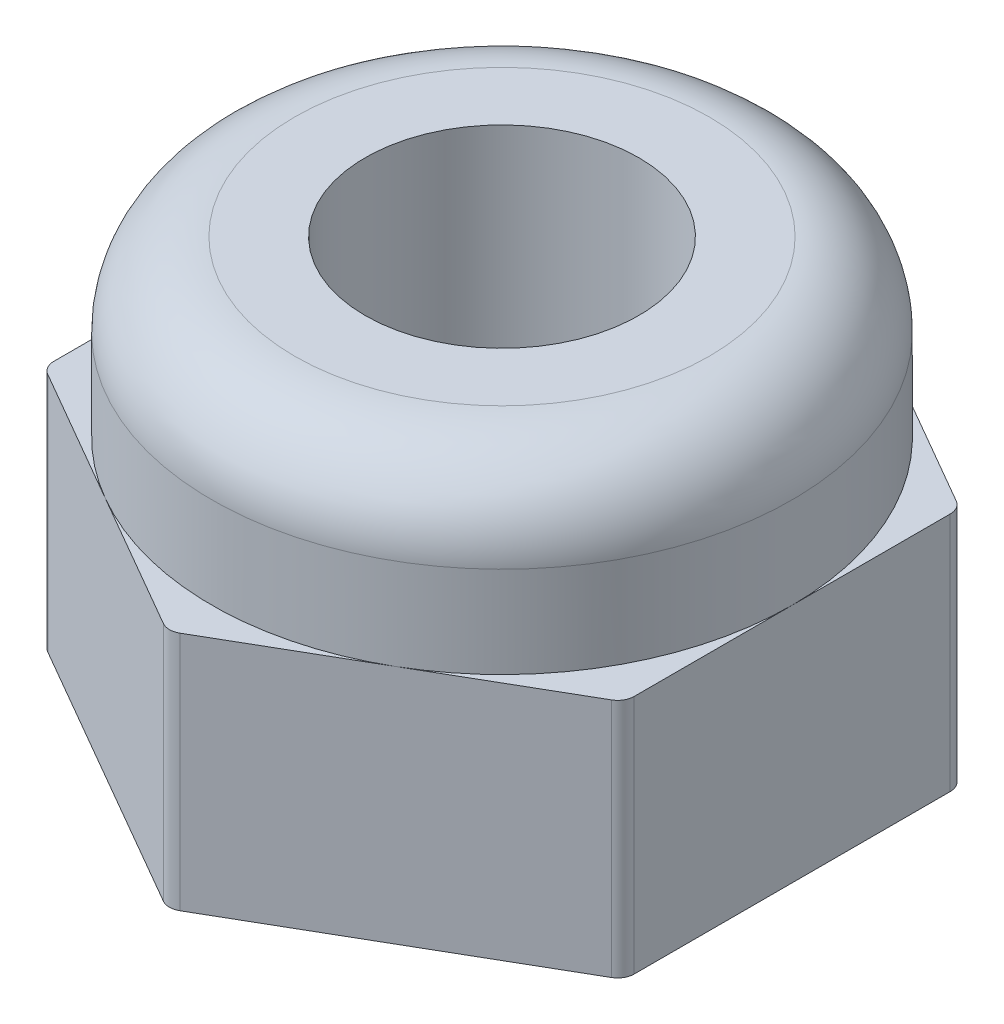
from build123d import *

# Parameters (mm, degrees)
EXTRUDE_1_DEPTH              = 2.9
SKETCH_2_R                   = 3.5
EXTRUDE_2_DEPTH              = 5
FILLET_1_R                   = 1
FILLET_2_R                   = 0.2
HOLE_WIZARD_M4_1_D           = 3.3
HOLE_WIZARD_M4_1_DEPTH       = 10.1
HOLE_WIZARD_M4_1_CSINK_D     = 4.05
HOLE_WIZARD_M4_1_CSINK_ANGLE = 90
HOLE_WIZARD_M4_1_TIP         = 0.991420021


with BuildPart() as part:
    # 草图1 → 凸台-拉伸1 (new body)
    with BuildSketch(Plane(origin=(0, 0, 0), x_dir=(1, 0, 0), z_dir=(0, 1, 0))):
        Polygon((3.5, -2.020725942), (3.5, 2.020725942), (0, 4.041451884), (-3.5, 2.020725942), (-3.5, -2.020725942), (0, -4.041451884), align=None)
    extrude(amount=EXTRUDE_1_DEPTH)

    # 草图2 → 凸台-拉伸2 (add)
    with BuildSketch(Plane.XZ):
        Circle(SKETCH_2_R)
    extrude(amount=-EXTRUDE_2_DEPTH)

    # 圆角1
    fillet_1_edges = [part.edges().sort_by_distance(p)[0] for p in [
        (-3.5, 5, 0),
    ]]
    fillet(fillet_1_edges, radius=FILLET_1_R)

    # 圆角2
    fillet_2_edges = [part.edges().sort_by_distance(p)[0] for p in [
        (0, 1.45, 4.041451884),
        (-3.5, 1.45, 2.020725942),
        (-3.5, 1.45, -2.020725942),
        (0, 1.45, -4.041451884),
        (3.5, 1.45, -2.020725942),
        (3.5, 1.45, 2.020725942),
    ]]
    fillet(fillet_2_edges, radius=FILLET_2_R)

    # M4 螺纹孔1
    with Locations(Plane(origin=(0, 0, 0), x_dir=(-1, 0, 0), z_dir=(0, -1, 0))):
        with Locations((0, 0)):
            CounterSinkHole(HOLE_WIZARD_M4_1_D / 2, HOLE_WIZARD_M4_1_CSINK_D / 2, depth=HOLE_WIZARD_M4_1_DEPTH, counter_sink_angle=HOLE_WIZARD_M4_1_CSINK_ANGLE)
            with Locations((0, 0, -(HOLE_WIZARD_M4_1_DEPTH + HOLE_WIZARD_M4_1_TIP / 2))):  # 118° drill point
                Cone(0, HOLE_WIZARD_M4_1_D / 2, HOLE_WIZARD_M4_1_TIP, mode=Mode.SUBTRACT)


solid = part.part
